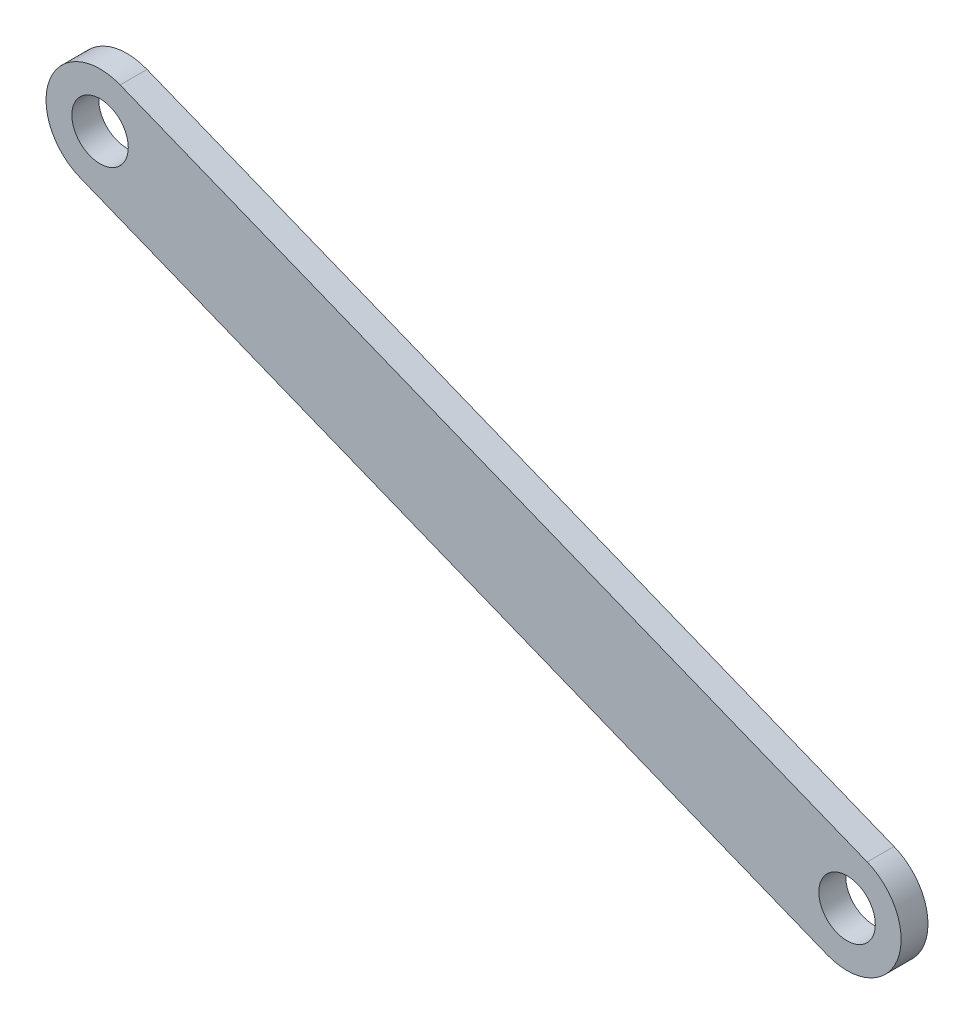
from build123d import *

# Parameters (mm, degrees)
BOSS_EXTRUDE1_DEPTH  = 4
M8_CLEARANCE_HOLE1_D = 8.4


with BuildPart() as part:
    # Sketch2 → Boss-Extrude1 (new body)
    with BuildSketch(Plane.XY):
        with BuildLine():
            Line((-242.044749956, -14.978446413), (-130.839092357, -59.549471623))
            ThreePointArc((-130.839092357, -59.549471623), (-126.366638289, -70.005056559), (-136.822223226, -74.477510627))
            Line((-136.822223226, -74.477510627), (-248.027880825, -29.906485416))
            ThreePointArc((-248.027880825, -29.906485416), (-252.500334893, -19.45090048), (-242.044749956, -14.978446413))
        make_face()
    extrude(amount=BOSS_EXTRUDE1_DEPTH)

    # M8 Clearance Hole1 (through all)
    with Locations(Plane.XY.offset(4)):
        with Locations((-245.036315391, -22.442465915), (-133.830657791, -67.013491125)):
            Hole(M8_CLEARANCE_HOLE1_D / 2)


solid = part.part
